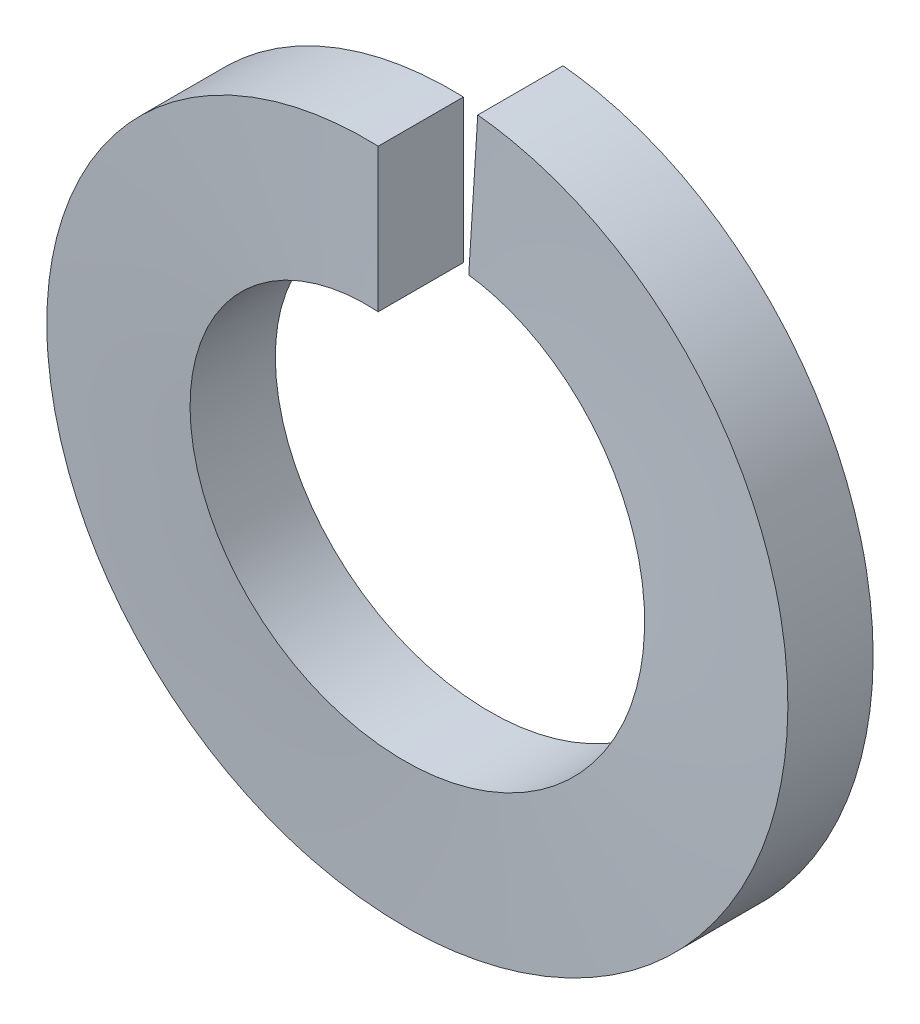
from build123d import *

# Parameters (mm, degrees)
SWEEP1_PITCH       = 2.02020202
SWEEP1_HEIGHT      = 2
SWEEP1_RADIUS      = 9.05
SWEEP1_START_ANGLE = 90
SKETCH4_W          = 2.2
SKETCH4_H          = 3.7


with BuildPart() as part:
    # Sweep1: sweep along a helix
    with BuildLine() as sweep1_path:
        add(Helix(SWEEP1_PITCH, SWEEP1_HEIGHT, SWEEP1_RADIUS, center=(0, 0, 0), direction=(0, 0, -1), lefthand=True, mode=Mode.PRIVATE).rotate(Axis((0, 0, 0), (0, 0, -1)), SWEEP1_START_ANGLE))
    # Sketch4 → Sweep1 (sweep)
    with BuildSketch(Plane(origin=(0, 0, 0), x_dir=(0, 0, -1), z_dir=(1, 0, 0))):
        with Locations((-1.1, 7.2)):
            Rectangle(SKETCH4_W, SKETCH4_H)
    sweep(path=sweep1_path.line, is_frenet=True)


solid = part.part
